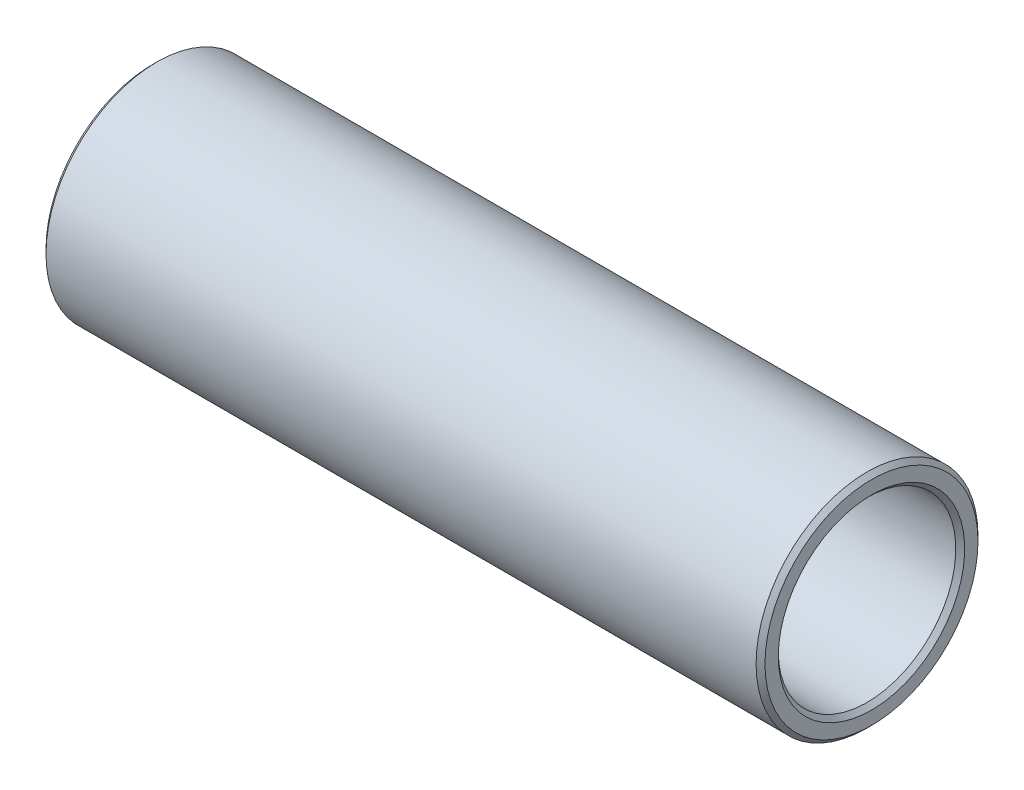
from build123d import *

# Parameters (mm, degrees)
SKETCH_1_W     = 81
SKETCH_1_H     = 2.5
CHAMFER_1_SIZE = 0.5


with BuildPart() as part:
    # Эскиз1 → Повернуть1 (revolve)
    with BuildSketch(Plane.XY):
        with Locations((40.5, 11.25)):
            Rectangle(SKETCH_1_W, SKETCH_1_H)
    revolve(axis=Axis((0, 0, 0), (1, 0, 0)))

    # Фаска1
    chamfer_1_edges = [part.edges().sort_by_distance(p)[0] for p in [
        (81, -12.5, 0),
        (81, -10, 0),
        (0, -10, 0),
        (0, -12.5, 0),
    ]]
    chamfer(chamfer_1_edges, length=CHAMFER_1_SIZE)


solid = part.part
